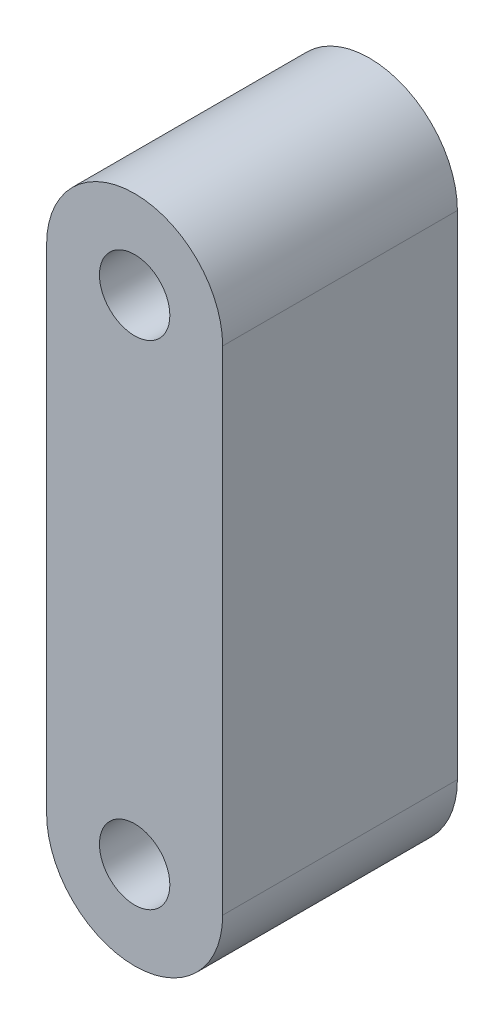
from build123d import *

# Parameters (mm, degrees)
SKETCH1_R           = 1.5
BOSS_EXTRUDE1_DEPTH = 10


with BuildPart() as part:
    # Sketch1 → Boss-Extrude1 (new body)
    with BuildSketch(Plane.XY):
        with BuildLine():
            Line((-3.75, 0), (-3.75, 21))
            ThreePointArc((-3.75, 21), (0, 24.75), (3.75, 21))
            Line((3.75, 21), (3.75, 0))
            ThreePointArc((3.75, 0), (0, -3.75), (-3.75, 0))
        make_face()
        with Locations((0, 21)):
            Circle(SKETCH1_R, mode=Mode.SUBTRACT)
        Circle(SKETCH1_R, mode=Mode.SUBTRACT)
    extrude(amount=BOSS_EXTRUDE1_DEPTH)


solid = part.part
